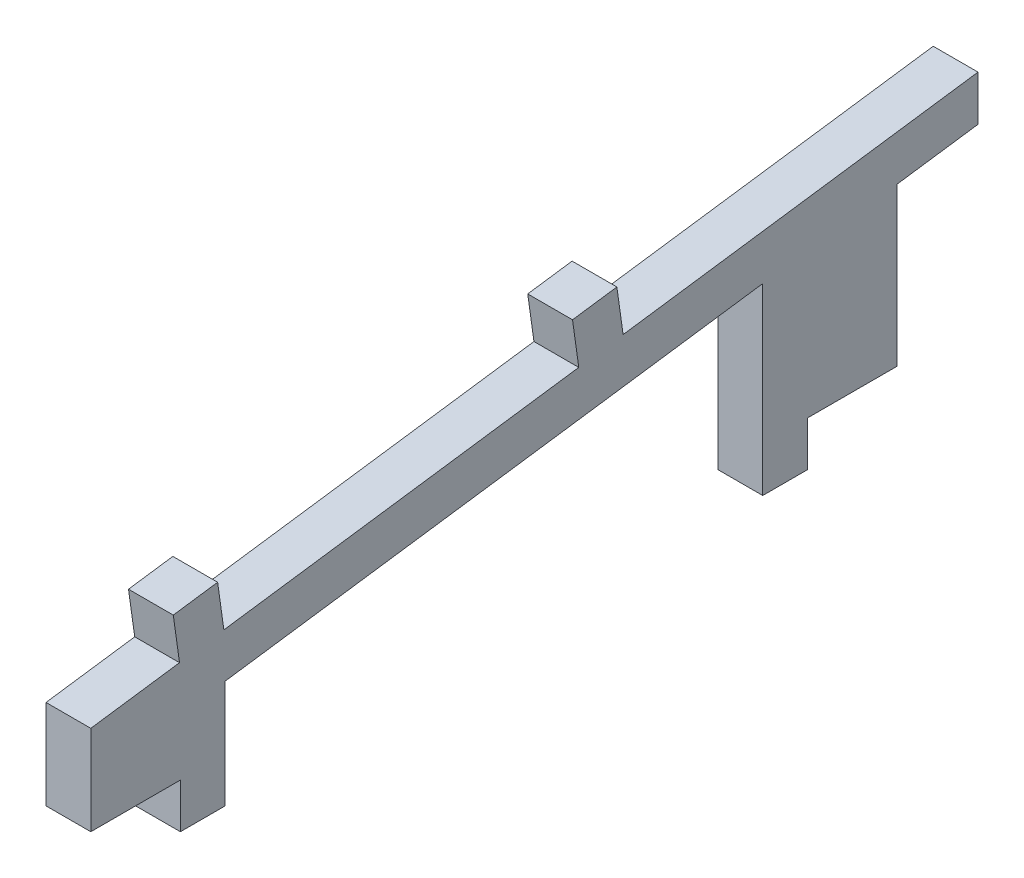
from build123d import *

# Parameters (mm, degrees)
BOSS_EXTRUDE1_DEPTH = 5


with BuildPart() as part:
    # Sketch1 → Boss-Extrude1 (new body)
    with BuildSketch(Plane(origin=(0, 0, 0), x_dir=(0, 0, -1), z_dir=(1, 0, 0))):
        Polygon((0, 0), (0, 10), (9.902680687, 11.39173101), (9.206815183, 16.343071353), (14.158155526, 17.038936858), (14.854021031, 12.087596514), (54.464743781, 17.654520553), (53.768878276, 22.605860897), (58.72021862, 23.301726401), (59.416084124, 18.350386058), (99.026806874, 23.917310096), (99.026806874, 18.868172233), (90, 17.599537261), (90, 0), (80, 0), (80, -5), (75, -5), (75, 15.49142474), (15, 7.058974658), (15, -5), (10, -5), (10, 0), align=None)
    extrude(amount=BOSS_EXTRUDE1_DEPTH)


solid = part.part
